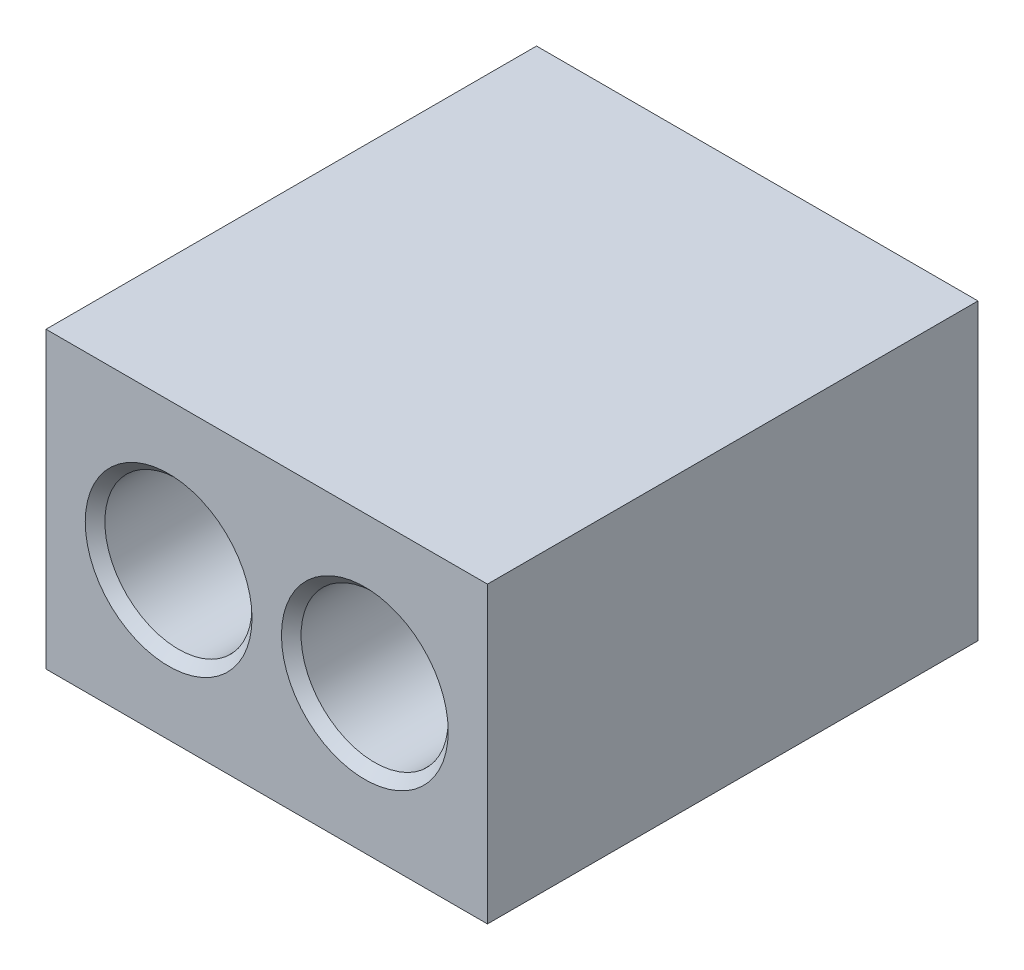
from build123d import *

# Parameters (mm, degrees)
SKETCH1_W           = 45
SKETCH1_H           = 30
SKETCH1_R           = 7.5
BOSS_EXTRUDE1_DEPTH = 25
CHAMFER1_SIZE       = 1


with BuildPart() as part:
    # Sketch1 → Boss-Extrude1 (new body, symmetric)
    with BuildSketch(Plane.XY):
        Rectangle(SKETCH1_W, SKETCH1_H)
        with Locations((-10, 0)):
            Circle(SKETCH1_R, mode=Mode.SUBTRACT)
        with Locations((10, 0)):
            Circle(SKETCH1_R, mode=Mode.SUBTRACT)
    extrude(amount=BOSS_EXTRUDE1_DEPTH, both=True)

    # Chamfer1
    chamfer1_edges = [part.edges().sort_by_distance(p)[0] for p in [
        (-17.5, 0, -25),
        (-17.5, 0, 25),
        (2.5, 0, -25),
        (2.5, 0, 25),
    ]]
    chamfer(chamfer1_edges, length=CHAMFER1_SIZE)


solid = part.part
